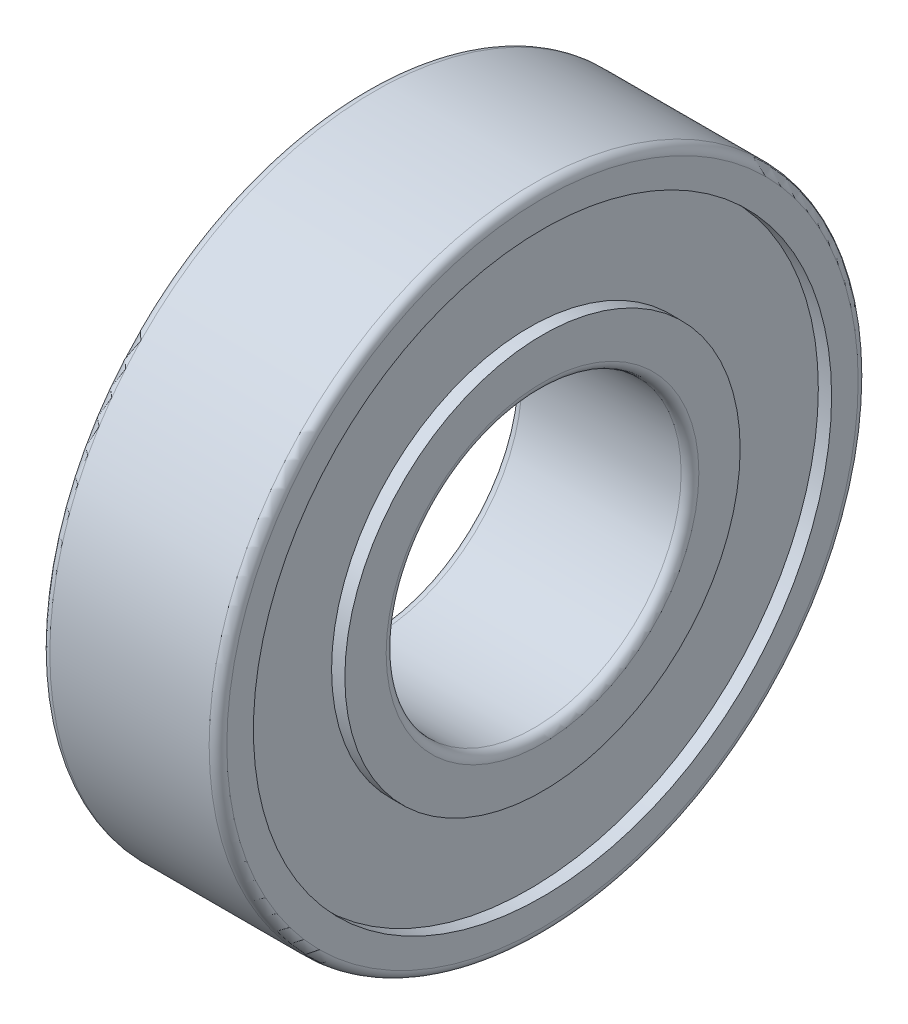
from build123d import *


with BuildPart() as part:
    # Sketch1 → Revolve1 (revolve)
    with BuildSketch(Plane.XY):
        with BuildLine():
            Line((0.3, 5), (5.7, 5))
            ThreePointArc((5.7, 5), (5.912132034, 5.087867966), (6, 5.3))
            Line((6, 5.3), (6, 6.7))
            Line((6, 6.7), (5.55, 6.7))
            Line((5.55, 6.7), (5.55, 9.8))
            Line((5.55, 9.8), (6, 9.8))
            Line((6, 9.8), (6, 10.7))
            ThreePointArc((6, 10.7), (5.912132034, 10.912132034), (5.7, 11))
            Line((5.7, 11), (0.3, 11))
            ThreePointArc((0.3, 11), (0.087867966, 10.912132034), (0, 10.7))
            Line((0, 10.7), (0, 9.8))
            Line((0, 9.8), (0.45, 9.8))
            Line((0.45, 9.8), (0.45, 6.7))
            Line((0.45, 6.7), (0, 6.7))
            Line((0, 6.7), (0, 5.3))
            ThreePointArc((0, 5.3), (0.087867966, 5.087867966), (0.3, 5))
        make_face()
    revolve(axis=Axis((-0.001253994, 0, 0), (1, 0, 0)))


solid = part.part
